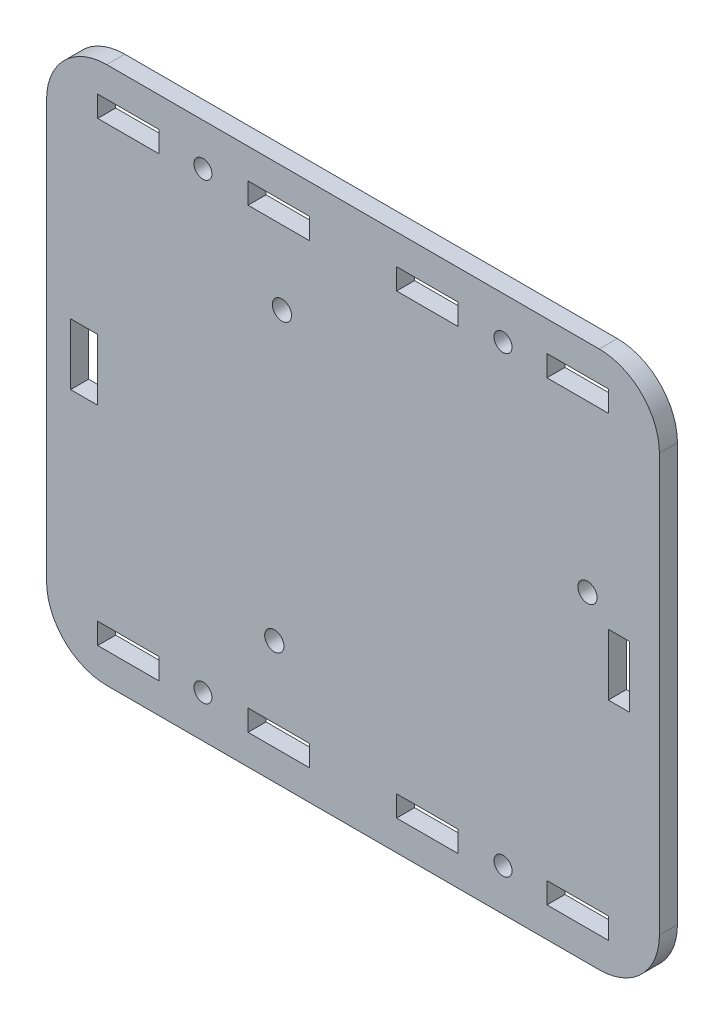
from build123d import *

# Parameters (mm, degrees)
MODEL_R             = 1.6
MODEL_R_2           = 1.5
MODEL_W             = 10.2
MODEL_H             = 3.5
MODEL_W_2           = 4.5
MODEL_H_2           = 10.2
MODEL_W_3           = 3.5
BOSS_EXTRUDE1_DEPTH = 3


with BuildPart() as part:
    # Model → Boss-Extrude1 (new body)
    with BuildSketch(Plane.XY):
        with BuildLine():
            Line((6.5, -85.9), (88.4, -85.9))
            ThreePointArc((88.4, -85.9), (95.471067812, -82.971067812), (98.4, -75.9))
            Line((98.4, -75.9), (98.4, -6.5))
            ThreePointArc((98.4, -6.5), (95.471067812, 0.571067812), (88.4, 3.5))
            Line((88.4, 3.5), (6.5, 3.5))
            ThreePointArc((6.5, 3.5), (-0.571067812, 0.571067812), (-3.5, -6.5))
            Line((-3.5, -6.5), (-3.5, -75.9))
            ThreePointArc((-3.5, -75.9), (-0.571067812, -82.971067812), (6.5, -85.9))
        make_face()
        with Locations((35.64, -17.27)):
            Circle(MODEL_R, mode=Mode.SUBTRACT)
        with Locations((34.37, -65.53)):
            Circle(MODEL_R, mode=Mode.SUBTRACT)
        with Locations((22.5, -78.9)):
            Circle(MODEL_R_2, mode=Mode.SUBTRACT)
        with Locations((72.4, -3.5)):
            Circle(MODEL_R_2, mode=Mode.SUBTRACT)
        with Locations((22.5, -3.5)):
            Circle(MODEL_R_2, mode=Mode.SUBTRACT)
        with Locations((72.4, -78.9)):
            Circle(MODEL_R_2, mode=Mode.SUBTRACT)
        with Locations((86.44, -32.51)):
            Circle(MODEL_R, mode=Mode.SUBTRACT)
        with Locations((59.8, -79.15)):
            Rectangle(MODEL_W, MODEL_H, mode=Mode.SUBTRACT)
        with Locations((10.1, -79.15)):
            Rectangle(MODEL_W, MODEL_H, mode=Mode.SUBTRACT)
        with Locations((59.8, -3.25)):
            Rectangle(MODEL_W, MODEL_H, mode=Mode.SUBTRACT)
        with Locations((10.1, -3.25)):
            Rectangle(MODEL_W, MODEL_H, mode=Mode.SUBTRACT)
        with Locations((2.75, -41.2)):
            Rectangle(MODEL_W_2, MODEL_H_2, mode=Mode.SUBTRACT)
        with Locations((91.65, -41.2)):
            Rectangle(MODEL_W_3, MODEL_H_2, mode=Mode.SUBTRACT)
        with Locations((35.1, -3.25)):
            Rectangle(MODEL_W, MODEL_H, mode=Mode.SUBTRACT)
        with Locations((84.8, -3.25)):
            Rectangle(MODEL_W, MODEL_H, mode=Mode.SUBTRACT)
        with Locations((35.1, -79.15)):
            Rectangle(MODEL_W, MODEL_H, mode=Mode.SUBTRACT)
        with Locations((84.8, -79.15)):
            Rectangle(MODEL_W, MODEL_H, mode=Mode.SUBTRACT)
    extrude(amount=BOSS_EXTRUDE1_DEPTH)


solid = part.part
